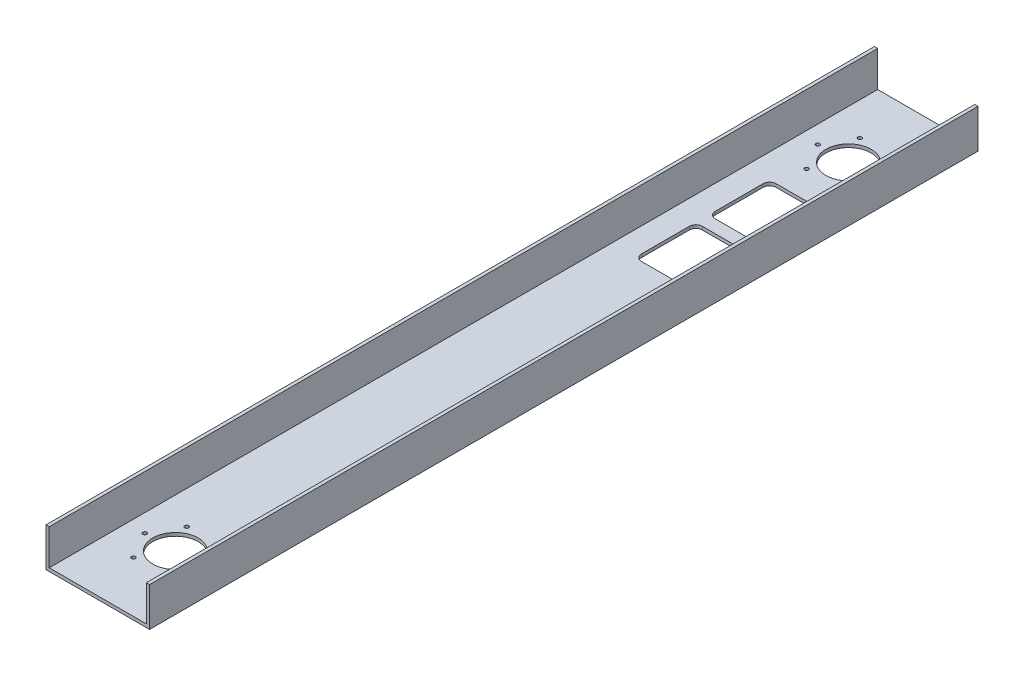
from build123d import *

# Parameters (mm, degrees)
BOSS_EXTRUDE1_DEPTH = 812.8
SKETCH2_R           = 22.2377
CUT_EXTRUDE1_DEPTH  = 3.175
SKETCH3_R           = 1.89865
CUT_EXTRUDE2_DEPTH  = 3.175
CUT_EXTRUDE3_REACH  = 40.1


with BuildPart() as part:
    # Sketch1 → Boss-Extrude1 (new body)
    with BuildSketch(Plane.XY):
        Polygon((3.175, 3.175), (3.175, 38.1), (0, 38.1), (0, 0), (101.6, 0), (101.6, 38.1), (98.425, 38.1), (98.425, 3.175), align=None)
    extrude(amount=BOSS_EXTRUDE1_DEPTH)

    # Sketch2 → Cut-Extrude1 (cut)
    with BuildSketch(Plane.XZ):
        with Locations((50.8, 736.6)):
            Circle(SKETCH2_R)
    cut_extrude1 = extrude(amount=-CUT_EXTRUDE1_DEPTH, mode=Mode.SUBTRACT)

    # Sketch3 → Cut-Extrude2 (cut)
    with BuildSketch(Plane.XZ):
        with Locations((65.88125, 762.721491242)):
            Circle(SKETCH3_R)
        with Locations((80.9625, 736.6)):
            Circle(SKETCH3_R)
        with Locations((65.88125, 710.478508758)):
            Circle(SKETCH3_R)
        with Locations((35.71875, 710.478508758)):
            Circle(SKETCH3_R)
        with Locations((20.6375, 736.6)):
            Circle(SKETCH3_R)
        with Locations((35.71875, 762.721491242)):
            Circle(SKETCH3_R)
    cut_extrude2 = extrude(amount=-CUT_EXTRUDE2_DEPTH, mode=Mode.SUBTRACT)

    # Mirror1: Cut-Extrude1, Cut-Extrude2 across plane
    add(cut_extrude1.mirror(Plane.XY.offset(406.4)), mode=Mode.SUBTRACT)
    add(cut_extrude2.mirror(Plane.XY.offset(406.4)), mode=Mode.SUBTRACT)

    # Sketch4 → Cut-Extrude3 (cut, up to next)
    with BuildSketch(Plane.XZ, mode=Mode.PRIVATE) as cut_extrude3_sk1:
        with BuildLine():
            Line((68.2625, 129.836281806), (33.3375, 129.836281806))
            ThreePointArc((33.3375, 129.836281806), (28.847371939, 131.696153745), (26.9875, 136.186281806))
            Line((26.9875, 136.186281806), (26.9875, 183.200007549))
            ThreePointArc((26.9875, 183.200007549), (28.847371939, 187.690135609), (33.3375, 189.550007549))
            Line((33.3375, 189.550007549), (68.2625, 189.550007549))
            ThreePointArc((68.2625, 189.550007549), (72.752628061, 187.690135609), (74.6125, 183.200007549))
            Line((74.6125, 183.200007549), (74.6125, 136.186281806))
            ThreePointArc((74.6125, 136.186281806), (72.752628061, 131.696153745), (68.2625, 129.836281806))
        make_face()
    cut_extrude3_tool1 = extrude(cut_extrude3_sk1.sketch, amount=-CUT_EXTRUDE3_REACH, mode=Mode.PRIVATE) & part.part
    add(cut_extrude3_tool1.solids().sort_by_distance((50.8, 0, 159.693145))[0], mode=Mode.SUBTRACT)
    # Sketch4 → Cut-Extrude3 (cut, up to next)
    with BuildSketch(Plane.XZ, mode=Mode.PRIVATE) as cut_extrude3_sk2:
        with BuildLine():
            Line((68.2625, 261.963733292), (33.3375, 261.963733292))
            ThreePointArc((33.3375, 261.963733292), (28.847371939, 260.103861353), (26.9875, 255.613733292))
            Line((26.9875, 255.613733292), (26.9875, 208.600007549))
            ThreePointArc((26.9875, 208.600007549), (28.847371939, 204.109879488), (33.3375, 202.250007549))
            Line((33.3375, 202.250007549), (68.2625, 202.250007549))
            ThreePointArc((68.2625, 202.250007549), (72.752628061, 204.109879488), (74.6125, 208.600007549))
            Line((74.6125, 208.600007549), (74.6125, 255.613733292))
            ThreePointArc((74.6125, 255.613733292), (72.752628061, 260.103861353), (68.2625, 261.963733292))
        make_face()
    cut_extrude3_tool2 = extrude(cut_extrude3_sk2.sketch, amount=-CUT_EXTRUDE3_REACH, mode=Mode.PRIVATE) & part.part
    add(cut_extrude3_tool2.solids().sort_by_distance((50.8, 0, 232.10687))[0], mode=Mode.SUBTRACT)


solid = part.part
